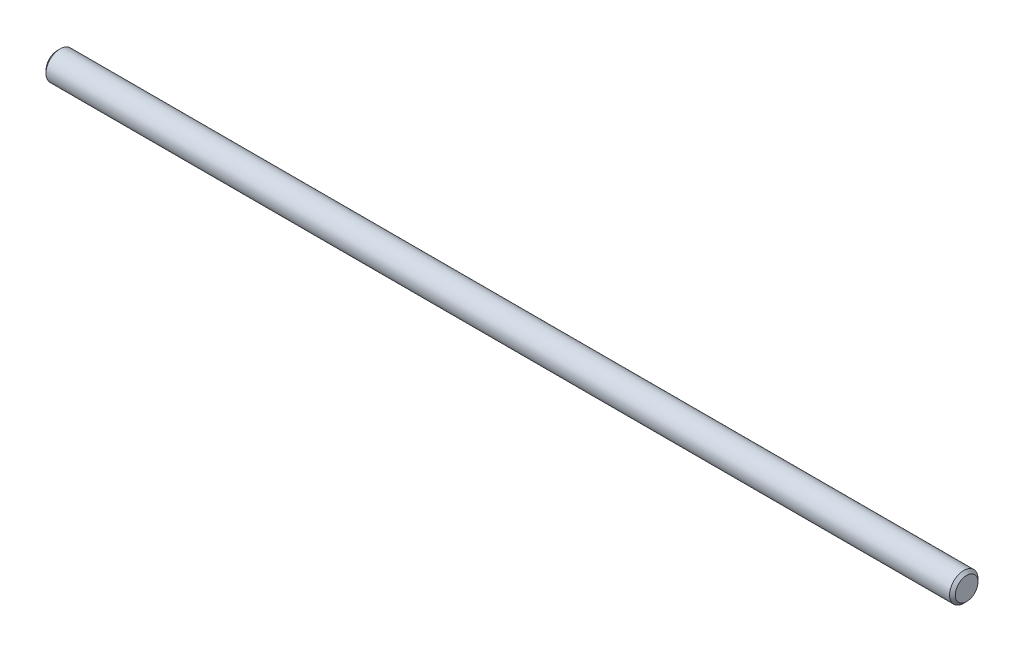
from build123d import *

# Parameters (mm, degrees)
SKETCH2_R           = 3.175
EXTRUDE1_DEPTH      = 101.6
EXTRUDE1_DEPTH_BACK = 101.6
CHAMFER1_SIZE       = 0.635


with BuildPart() as part:
    # Sketch2 → Extrude1 (new body, two sides)
    with BuildSketch(Plane(origin=(0, 0, 0), x_dir=(0, 0, -1), z_dir=(1, 0, 0))) as extrude1_sk:
        Circle(SKETCH2_R)
    extrude(amount=EXTRUDE1_DEPTH)
    extrude(extrude1_sk.sketch, amount=-EXTRUDE1_DEPTH_BACK)

    # Chamfer1
    chamfer1_edges = [part.edges().sort_by_distance(p)[0] for p in [
        (-101.6, 0, 3.175),
        (101.6, 0, 3.175),
    ]]
    chamfer(chamfer1_edges, length=CHAMFER1_SIZE)


solid = part.part
